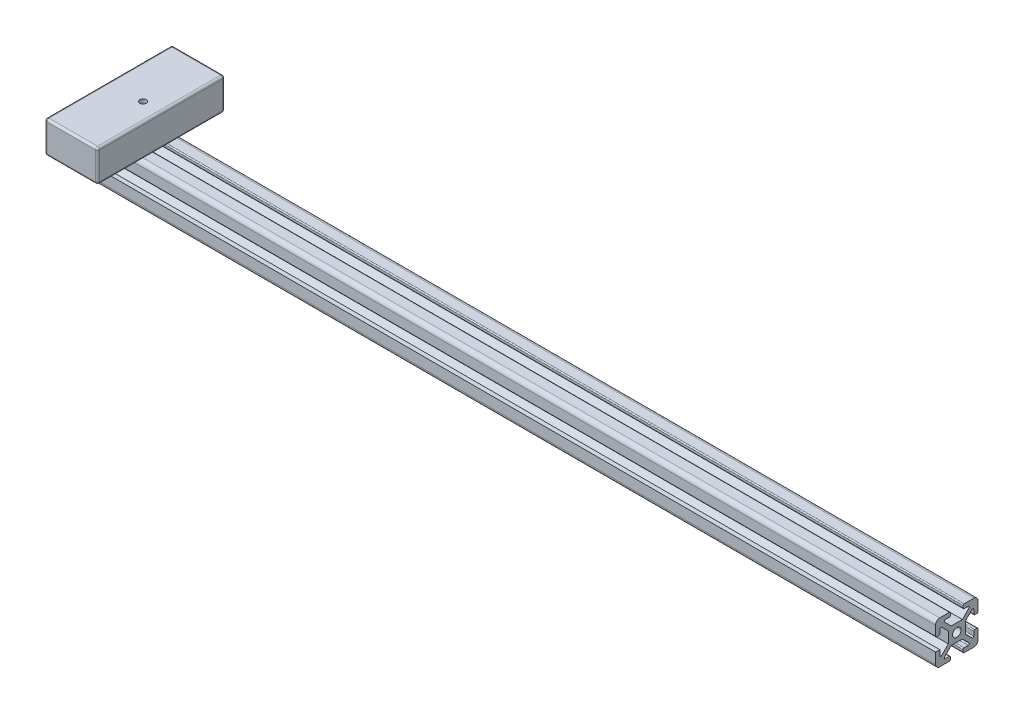
from build123d import *

# Parameters (mm, degrees)
SKETCH2_R                       = 2
ALUMINIUM_PROFILE_20_20_1_DEPTH = 400
SKETCH3_R                       = 2
CUT_EXTRUDE1_DEPTH              = 40
SKETCH4_W                       = 24.878997643
SKETCH4_H                       = 60
BOSS_EXTRUDE1_DEPTH             = 15
FILLET1_R                       = 1
SKETCH6_R                       = 1.5
CUT_EXTRUDE2_DEPTH              = 40


with BuildPart() as part:
    # Sketch2 → Aluminium profile 20×20(1) (new body)
    with BuildSketch(Plane.YZ):
        with BuildLine():
            Line((-2.666639653, -4), (2.666639653, -4))
            Line((2.666639653, -4), (5.776647091, -7.148635412))
            ThreePointArc((5.776647091, -7.148635412), (5.882265465, -7.692766317), (5.420918365, -8))
            Line((5.420918365, -8), (3.498570355, -8))
            ThreePointArc((3.498570355, -8), (3.145016964, -8.146446609), (2.998570355, -8.5))
            Line((2.998570355, -8.5), (2.998570355, -9.5))
            ThreePointArc((2.998570355, -9.5), (3.145016964, -9.853553391), (3.498570355, -10))
            Line((3.498570355, -10), (7.998570355, -10))
            ThreePointArc((7.998570355, -10), (9.412783917, -9.414213562), (9.998570355, -8))
            Line((9.998570355, -8), (9.998570355, -3.5))
            ThreePointArc((9.998570355, -3.5), (9.852123746, -3.146446609), (9.498570355, -3))
            Line((9.498570355, -3), (8.498570355, -3))
            ThreePointArc((8.498570355, -3), (8.145016964, -3.146446609), (7.998570355, -3.5))
            Line((7.998570355, -3.5), (7.998570355, -5.412091861))
            ThreePointArc((7.998570355, -5.412091861), (7.691000546, -5.873579263), (7.146687869, -5.767308297))
            Line((7.146687869, -5.767308297), (4, -2.650154242))
            Line((4, -2.650154242), (4, 2.650154242))
            Line((4, 2.650154242), (7.146687869, 5.767308297))
            ThreePointArc((7.146687869, 5.767308297), (7.691000546, 5.873579263), (7.998570355, 5.412091861))
            Line((7.998570355, 5.412091861), (7.998570355, 3.5))
            ThreePointArc((7.998570355, 3.5), (8.145016964, 3.146446609), (8.498570355, 3))
            Line((8.498570355, 3), (9.498570355, 3))
            ThreePointArc((9.498570355, 3), (9.852123746, 3.146446609), (9.998570355, 3.5))
            Line((9.998570355, 3.5), (9.998570355, 8))
            ThreePointArc((9.998570355, 8), (9.412783917, 9.414213562), (7.998570355, 10))
            Line((7.998570355, 10), (3.498570355, 10))
            ThreePointArc((3.498570355, 10), (3.145016964, 9.853553391), (2.998570355, 9.5))
            Line((2.998570355, 9.5), (2.998570355, 8.5))
            ThreePointArc((2.998570355, 8.5), (3.145016964, 8.146446609), (3.498570355, 8))
            Line((3.498570355, 8), (5.420918365, 8))
            ThreePointArc((5.420918365, 8), (5.882265465, 7.692766317), (5.776647091, 7.148635412))
            Line((5.776647091, 7.148635412), (2.666639653, 4))
            Line((2.666639653, 4), (-2.666639653, 4))
            Line((-2.666639653, 4), (-5.776647091, 7.148635412))
            ThreePointArc((-5.776647091, 7.148635412), (-5.882265465, 7.692766317), (-5.420918365, 8))
            Line((-5.420918365, 8), (-2.998570355, 8))
            Line((-2.998570355, 8), (-2.998570355, 10))
            Line((-2.998570355, 10), (-7.998570355, 10))
            ThreePointArc((-7.998570355, 10), (-9.412783917, 9.414213562), (-9.998570355, 8))
            Line((-9.998570355, 8), (-9.998570355, 3.5))
            ThreePointArc((-9.998570355, 3.5), (-9.852123746, 3.146446609), (-9.498570355, 3))
            Line((-9.498570355, 3), (-8.498570355, 3))
            ThreePointArc((-8.498570355, 3), (-8.145016964, 3.146446609), (-7.998570355, 3.5))
            Line((-7.998570355, 3.5), (-7.998570355, 5.412091861))
            ThreePointArc((-7.998570355, 5.412091861), (-7.691000546, 5.873579263), (-7.146687869, 5.767308297))
            Line((-7.146687869, 5.767308297), (-4, 2.650154242))
            Line((-4, 2.650154242), (-4, -2.650154242))
            Line((-4, -2.650154242), (-7.146687869, -5.767308297))
            ThreePointArc((-7.146687869, -5.767308297), (-7.691000546, -5.873579263), (-7.998570355, -5.412091861))
            Line((-7.998570355, -5.412091861), (-7.998570355, -3.5))
            ThreePointArc((-7.998570355, -3.5), (-8.145016964, -3.146446609), (-8.498570355, -3))
            Line((-8.498570355, -3), (-9.498570355, -3))
            ThreePointArc((-9.498570355, -3), (-9.852123746, -3.146446609), (-9.998570355, -3.5))
            Line((-9.998570355, -3.5), (-9.998570355, -8))
            ThreePointArc((-9.998570355, -8), (-9.412783917, -9.414213562), (-7.998570355, -10))
            Line((-7.998570355, -10), (-3.498570355, -10))
            ThreePointArc((-3.498570355, -10), (-3.145016964, -9.853553391), (-2.998570355, -9.5))
            Line((-2.998570355, -9.5), (-2.998570355, -8.5))
            ThreePointArc((-2.998570355, -8.5), (-3.145016964, -8.146446609), (-3.498570355, -8))
            Line((-3.498570355, -8), (-5.420918365, -8))
            ThreePointArc((-5.420918365, -8), (-5.882265465, -7.692766317), (-5.776647091, -7.148635412))
            Line((-5.776647091, -7.148635412), (-2.666639653, -4))
        make_face()
        Circle(SKETCH2_R, mode=Mode.SUBTRACT)
    extrude(amount=ALUMINIUM_PROFILE_20_20_1_DEPTH)

    # Sketch3 → Cut-Extrude1 (cut)
    with BuildSketch(Plane.XY.offset(10)):
        with Locations((364, 0)):
            Circle(SKETCH3_R)
        with Locations((336, 0)):
            Circle(SKETCH3_R)
    extrude(amount=-CUT_EXTRUDE1_DEPTH, mode=Mode.SUBTRACT)


with BuildPart() as body_2:
    # Sketch4 → Boss-Extrude1 (new body)
    with BuildSketch(Plane(origin=(0, 9.998570355, 0), x_dir=(1, 0, 0), z_dir=(0, 1, 0))):
        with Locations((12.439498822, 0)):
            Rectangle(SKETCH4_W, SKETCH4_H)
    extrude(amount=BOSS_EXTRUDE1_DEPTH)

    # Fillet1
    fillet1_edges = [body_2.edges().sort_by_distance(p)[0] for p in [
        (24.878997643, 24.998570355, 0),
        (12.439498821, 24.998570355, -30),
        (0, 24.998570355, 0),
        (12.439498821, 9.998570355, -30),
        (24.878997643, 9.998570355, 0),
        (12.439498821, 9.998570355, 30),
        (0, 9.998570355, 0),
        (0, 17.498570355, -30),
        (24.878997643, 17.498570355, -30),
        (24.878997643, 17.498570355, 30),
        (0, 17.498570355, 30),
        (12.439498821, 24.998570355, 30),
    ]]
    fillet(fillet1_edges, radius=FILLET1_R)


with BuildPart() as cut_extrude2_tool:
    # Sketch6 → Cut-Extrude2 (new body)
    with BuildSketch(Plane(origin=(0, 24.998570355, 0), x_dir=(1, 0, 0), z_dir=(0, 1, 0))):
        with Locations(Location((16.342417806, 0, 0), (0, 0, 270))):
            Circle(SKETCH6_R)
    extrude(amount=-CUT_EXTRUDE2_DEPTH)


with BuildPart() as part_1:
    add(part.part)

    # Cut-Extrude2: cut by cut_extrude2_tool
    add(cut_extrude2_tool.part, mode=Mode.SUBTRACT)


with BuildPart() as body_2_1:
    add(body_2.part)

    # Cut-Extrude2: cut by cut_extrude2_tool
    add(cut_extrude2_tool.part, mode=Mode.SUBTRACT)


solid = Compound([part_1.part, body_2_1.part])
